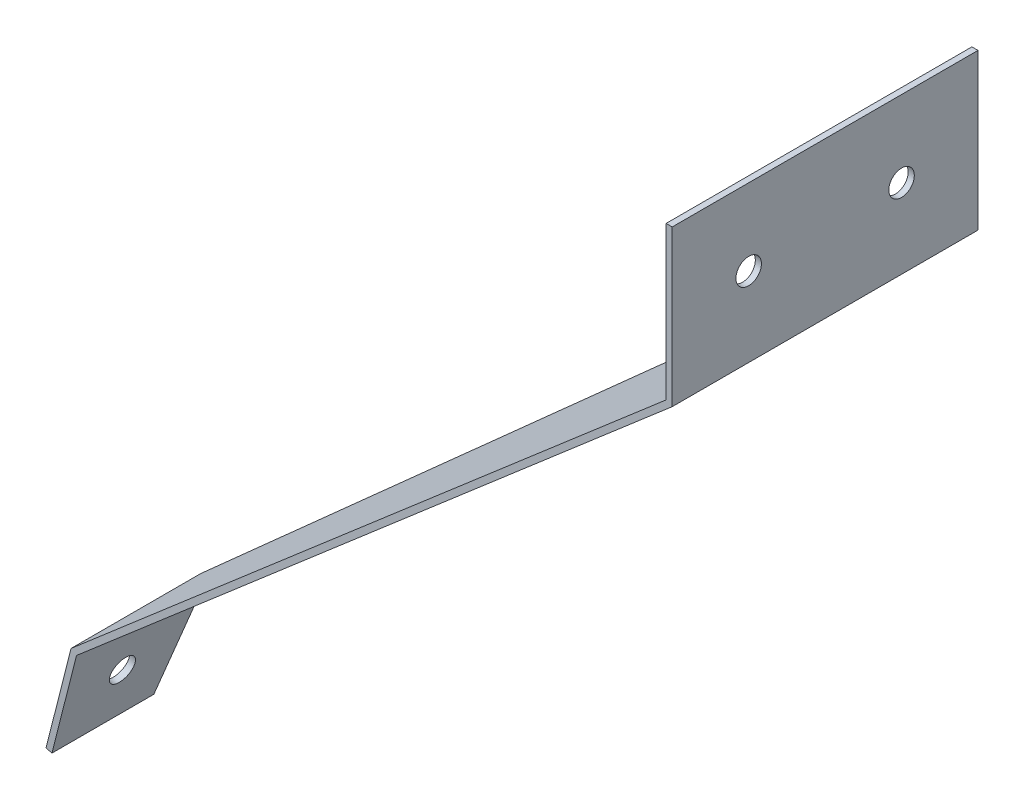
from build123d import *

# Parameters (mm, degrees)
BOSS_EXTRUDE1_DEPTH = 76.2
CUT_EXTRUDE1_DEPTH  = 152.364149309
SKETCH3_R           = 3.175
CUT_EXTRUDE2_DEPTH  = 152.364149309
SKETCH4_R           = 3.175
CUT_EXTRUDE3_DEPTH  = 2.524


with BuildPart() as part:
    # Sketch1 → Boss-Extrude1 (new body)
    with BuildSketch(Plane.XY):
        Polygon((0, 0), (0, 38.1), (1.524, 38.1), (1.524, -0.698546195), (-146.938943833, -128.622402846), (-153.072957039, -152.775137619), (-154.550064945, -152.4), (-148.297771302, -127.781534893), align=None)
    extrude(amount=BOSS_EXTRUDE1_DEPTH)

    # Sketch2 → Cut-Extrude1 (cut, through all)
    with BuildSketch(Plane(origin=(-108.826155859, 27.638322679, 0), x_dir=(0, 0, 1), z_dir=(-0.96923091, 0.246153293, 0))):
        Polygon((0, -185.753798063), (50.8, -185.753798063), (0, 0), align=None)
    extrude(amount=-CUT_EXTRUDE1_DEPTH, mode=Mode.SUBTRACT)

    # Sketch3 → Cut-Extrude2 (cut, through all)
    with BuildSketch(Plane(origin=(-108.826155859, 27.638322679, 0), x_dir=(0, 0, 1), z_dir=(-0.96923091, 0.246153293, 0))):
        with Locations((61.763400246, -173.053798063)):
            Circle(SKETCH3_R)
    extrude(amount=-CUT_EXTRUDE2_DEPTH, mode=Mode.SUBTRACT)

    # Sketch4 → Cut-Extrude3 (cut, through all)
    with BuildSketch(Plane.ZY):
        with Locations((19.05, 19.05)):
            Circle(SKETCH4_R)
        with Locations((57.15, 19.05)):
            Circle(SKETCH4_R)
    extrude(amount=-CUT_EXTRUDE3_DEPTH, mode=Mode.SUBTRACT)


solid = part.part
